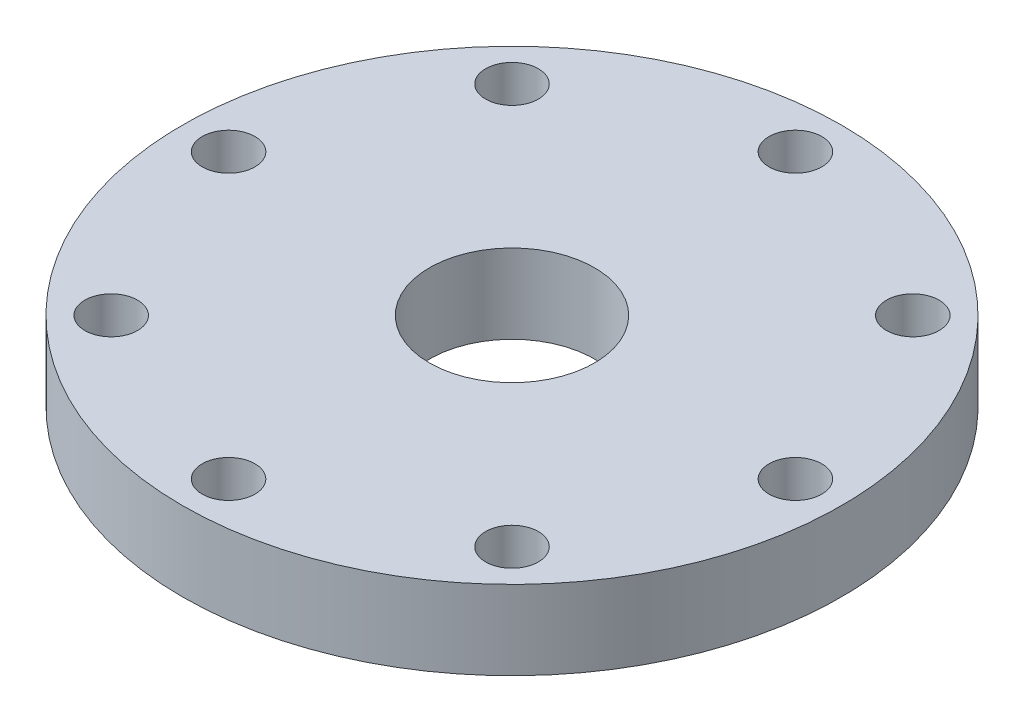
from build123d import *

# Parameters (mm, degrees)
SKETCH_1_R      = 25
SKETCH_1_R_2    = 2
SKETCH_1_R_3    = 6.260668566
EXTRUDE_1_DEPTH = 6


with BuildPart() as part:
    # 草图1 → 凸台-拉伸1 (new body)
    with BuildSketch(Plane(origin=(0, 0, 0), x_dir=(1, 0, 0), z_dir=(0, 1, 0))):
        Circle(SKETCH_1_R)
        with Locations((0, 21.5)):
            Circle(SKETCH_1_R_2, mode=Mode.SUBTRACT)
        with Locations((15.202795796, 15.202795796)):
            Circle(SKETCH_1_R_2, mode=Mode.SUBTRACT)
        with Locations((21.5, 0)):
            Circle(SKETCH_1_R_2, mode=Mode.SUBTRACT)
        with Locations((15.202795796, -15.202795796)):
            Circle(SKETCH_1_R_2, mode=Mode.SUBTRACT)
        with Locations((0, -21.5)):
            Circle(SKETCH_1_R_2, mode=Mode.SUBTRACT)
        with Locations((-15.202795796, -15.202795796)):
            Circle(SKETCH_1_R_2, mode=Mode.SUBTRACT)
        with Locations((-21.5, 0)):
            Circle(SKETCH_1_R_2, mode=Mode.SUBTRACT)
        with Locations((-15.202795796, 15.202795796)):
            Circle(SKETCH_1_R_2, mode=Mode.SUBTRACT)
        Circle(SKETCH_1_R_3, mode=Mode.SUBTRACT)
    extrude(amount=EXTRUDE_1_DEPTH)


solid = part.part
